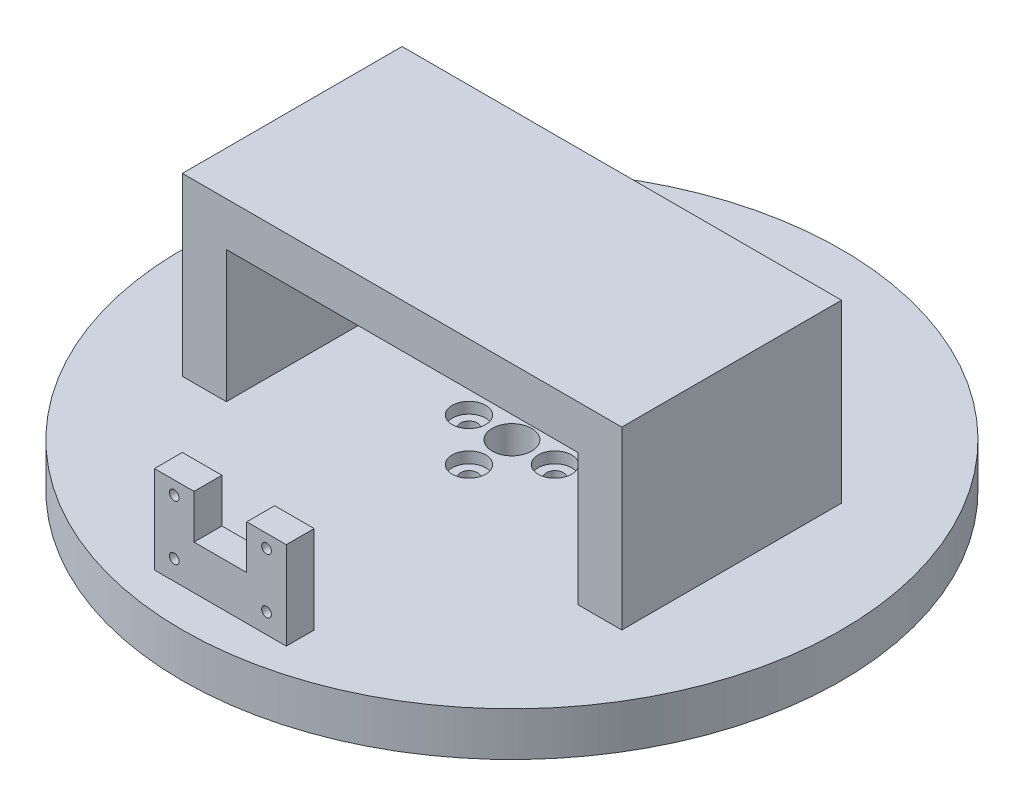
from build123d import *

# Parameters (mm, degrees)
SKETCH1_R           = 75
BOSS_EXTRUDE1_DEPTH = 10
SKETCH2_R           = 1.905
CUT_EXTRUDE2_DEPTH  = 11
CIRPATTERN1_COUNT   = 4
SKETCH3_R           = 4.5
CUT_EXTRUDE3_DEPTH  = 11
SKETCH4_R           = 3.81
CUT_EXTRUDE4_DEPTH  = 2.54
CIRPATTERN2_COUNT   = 4
SKETCH5_W           = 10
SKETCH5_H           = 50
BOSS_EXTRUDE2_DEPTH = 40
SKETCH6_W           = 50
SKETCH6_H           = 10
BOSS_EXTRUDE3_DEPTH = 40
SKETCH7_W           = 30
SKETCH7_H           = 6.35
BOSS_EXTRUDE4_DEPTH = 20
CUT_EXTRUDE5_REACH  = 143.35
SKETCH8_R           = 1.1
SKETCH8_W           = 12
SKETCH8_H           = 20


with BuildPart() as part:
    # Sketch1 → Boss-Extrude1 (new body)
    with BuildSketch(Plane(origin=(0, 0, 0), x_dir=(1, 0, 0), z_dir=(0, 1, 0))):
        Circle(SKETCH1_R)
    extrude(amount=BOSS_EXTRUDE1_DEPTH)

    # Sketch2 → Cut-Extrude2 (cut, through all)
    with BuildSketch(Plane(origin=(0, 10, 0), x_dir=(1, 0, 0), z_dir=(0, 1, 0))):
        with Locations((0, 9.779)):
            Circle(SKETCH2_R)
    cut_extrude2 = extrude(amount=-CUT_EXTRUDE2_DEPTH, mode=Mode.SUBTRACT)

    # CirPattern1: Cut-Extrude2 ×4 about axis
    cirpattern1_axis = Axis((0, 0, 0), (0, 1, 0))
    for i in range(1, CIRPATTERN1_COUNT):
        add(cut_extrude2.rotate(cirpattern1_axis, i * 360 / CIRPATTERN1_COUNT), mode=Mode.SUBTRACT)

    # Sketch3 → Cut-Extrude3 (cut, through all)
    with BuildSketch(Plane(origin=(0, 10, 0), x_dir=(1, 0, 0), z_dir=(0, 1, 0))):
        Circle(SKETCH3_R)
    extrude(amount=-CUT_EXTRUDE3_DEPTH, mode=Mode.SUBTRACT)

    # Sketch4 → Cut-Extrude4 (cut)
    with BuildSketch(Plane(origin=(0, 10, 0), x_dir=(1, 0, 0), z_dir=(0, 1, 0))):
        with Locations((0, 9.779)):
            Circle(SKETCH4_R)
    cut_extrude4 = extrude(amount=-CUT_EXTRUDE4_DEPTH, mode=Mode.SUBTRACT)

    # CirPattern2: Cut-Extrude4 ×4 about axis
    cirpattern2_axis = Axis((0, 0, 0), (0, 1, 0))
    for i in range(1, CIRPATTERN2_COUNT):
        add(cut_extrude4.rotate(cirpattern2_axis, i * 360 / CIRPATTERN2_COUNT), mode=Mode.SUBTRACT)

    # Sketch5 → Boss-Extrude2 (add)
    with BuildSketch(Plane(origin=(0, 10, 0), x_dir=(1, 0, 0), z_dir=(0, 1, 0))):
        with Locations((-45, 0)):
            Rectangle(SKETCH5_W, SKETCH5_H)
    boss_extrude2 = extrude(amount=BOSS_EXTRUDE2_DEPTH)

    # Sketch6 → Boss-Extrude3 (add)
    with BuildSketch(Plane(origin=(-40, 0, 0), x_dir=(0, 0, -1), z_dir=(1, 0, 0))):
        with Locations((0, 45)):
            Rectangle(SKETCH6_W, SKETCH6_H)
    boss_extrude3 = extrude(amount=BOSS_EXTRUDE3_DEPTH)

    # Mirror1: Boss-Extrude2, Boss-Extrude3 across plane
    add(boss_extrude2.mirror(Plane(origin=(0, 0, 0), x_dir=(0, 0, 1), z_dir=(1, 0, 0))))
    add(boss_extrude3.mirror(Plane(origin=(0, 0, 0), x_dir=(0, 0, 1), z_dir=(1, 0, 0))))

    # Sketch7 → Boss-Extrude4 (add)
    with BuildSketch(Plane(origin=(0, 10, 0), x_dir=(1, 0, 0), z_dir=(0, 1, 0))):
        with Locations((0, -63.175)):
            Rectangle(SKETCH7_W, SKETCH7_H)
    extrude(amount=BOSS_EXTRUDE4_DEPTH)

    # Sketch8 → Cut-Extrude5 (cut, up to next)
    with BuildSketch(Plane.XY.offset(66.35), mode=Mode.PRIVATE) as cut_extrude5_sk1:
        with Locations((-10.5, 27)):
            Circle(SKETCH8_R)
    cut_extrude5_tool1 = extrude(cut_extrude5_sk1.sketch, amount=-CUT_EXTRUDE5_REACH, mode=Mode.PRIVATE) & part.part
    add(cut_extrude5_tool1.solids().sort_by_distance((-10.5, 27, 66.35))[0], mode=Mode.SUBTRACT)
    # Sketch8 → Cut-Extrude5 (cut, up to next)
    with BuildSketch(Plane.XY.offset(66.35), mode=Mode.PRIVATE) as cut_extrude5_sk2:
        with Locations((-10.5, 14.5)):
            Circle(SKETCH8_R)
    cut_extrude5_tool2 = extrude(cut_extrude5_sk2.sketch, amount=-CUT_EXTRUDE5_REACH, mode=Mode.PRIVATE) & part.part
    add(cut_extrude5_tool2.solids().sort_by_distance((-10.5, 14.5, 66.35))[0], mode=Mode.SUBTRACT)
    # Sketch8 → Cut-Extrude5 (cut, up to next)
    with BuildSketch(Plane.XY.offset(66.35), mode=Mode.PRIVATE) as cut_extrude5_sk3:
        with Locations((10.5, 27)):
            Circle(SKETCH8_R)
    cut_extrude5_tool3 = extrude(cut_extrude5_sk3.sketch, amount=-CUT_EXTRUDE5_REACH, mode=Mode.PRIVATE) & part.part
    add(cut_extrude5_tool3.solids().sort_by_distance((10.5, 27, 66.35))[0], mode=Mode.SUBTRACT)
    # Sketch8 → Cut-Extrude5 (cut, up to next)
    with BuildSketch(Plane.XY.offset(66.35), mode=Mode.PRIVATE) as cut_extrude5_sk4:
        with Locations((10.5, 14.5)):
            Circle(SKETCH8_R)
    cut_extrude5_tool4 = extrude(cut_extrude5_sk4.sketch, amount=-CUT_EXTRUDE5_REACH, mode=Mode.PRIVATE) & part.part
    add(cut_extrude5_tool4.solids().sort_by_distance((10.5, 14.5, 66.35))[0], mode=Mode.SUBTRACT)
    # Sketch8 → Cut-Extrude5 (cut, up to next)
    with BuildSketch(Plane.XY.offset(66.35), mode=Mode.PRIVATE) as cut_extrude5_sk5:
        with Locations((0, 30)):
            Rectangle(SKETCH8_W, SKETCH8_H)
    cut_extrude5_tool5 = extrude(cut_extrude5_sk5.sketch, amount=-CUT_EXTRUDE5_REACH, mode=Mode.PRIVATE) & part.part
    add(cut_extrude5_tool5.solids().sort_by_distance((0, 30, 66.35))[0], mode=Mode.SUBTRACT)


solid = part.part
